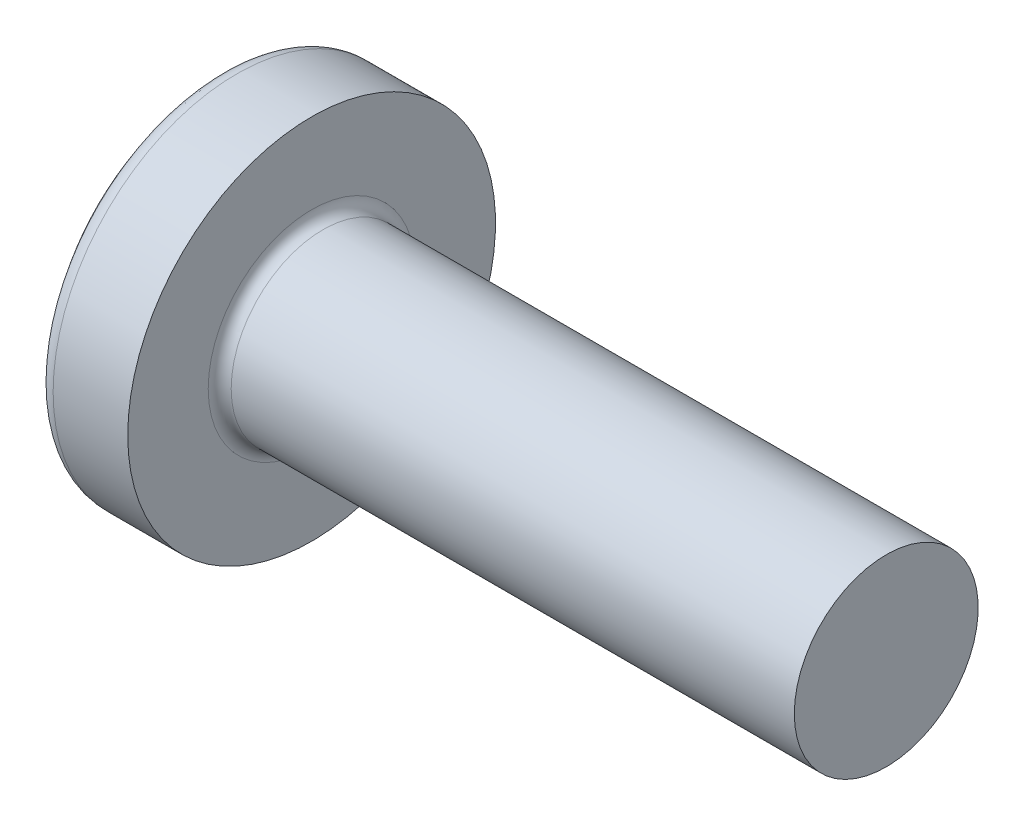
from build123d import *

# Parameters (mm, degrees)
FILLET1_R    = 0.1
SKETCH3_W    = 0.48
SKETCH3_H    = 1.6
SKETCH4_W    = 0.48
SKETCH4_H    = 0.702553256
RECPAT_COUNT = 2
RECPAT_ANGLE = 90


with BuildPart() as part:
    # BodySke → Base-Revolve (revolve)
    with BuildSketch(Plane.XY):
        with BuildLine():
            Line((1.3, 0.8), (1.3, 1.6))
            Line((1.3, 1.6), (0.650675799, 1.6))
            ThreePointArc((0.650675799, 1.6), (0.585036553, 1.584875829), (0.532633829, 1.542553191))
            ThreePointArc((0.532633829, 1.542553191), (0.136907172, 0.815960959), (0, 0))
            Line((0, 0), (6.3, 0))
            Line((6.3, 0), (6.3, 0.8))
            Line((6.3, 0.8), (1.3, 0.8))
        make_face()
    revolve(axis=Axis((-25.4, 0, 0), (1, 0, 0)))

    # Fillet1
    fillet1_edges = [part.edges().sort_by_distance(p)[0] for p in [
        (1.3, -0.8, 0),
    ]]
    fillet(fillet1_edges, radius=FILLET1_R)

    # Sketch3 → Recess section 0
    with BuildSketch(Plane(origin=(0, 0, 0), x_dir=(0, 0, -1), z_dir=(1, 0, 0))):
        Rectangle(SKETCH3_W, SKETCH3_H)
    # Sketch4 → Recess section 1
    with BuildSketch(Plane(origin=(0.9, 0, 0), x_dir=(0, 0, -1), z_dir=(1, 0, 0))):
        Rectangle(SKETCH4_W, SKETCH4_H)
    recess = loft(mode=Mode.SUBTRACT)

    # RecPat: Recess ×2 about axis
    recpat_axis = Axis((0, 0, 0), (1, 0, 0))
    for i in range(1, RECPAT_COUNT):
        add(recess.rotate(recpat_axis, i * RECPAT_ANGLE / (RECPAT_COUNT - 1)), mode=Mode.SUBTRACT)

    # RecCorSke → RecessCore (revolve, cut)
    with BuildSketch(Plane.XY):
        Polygon((0, 0), (0, 0.418434131), (0.9, 0.3555), (1.015508952, 0), align=None)
    revolve(axis=Axis((-3.175, 0, 0), (1, 0, 0)), mode=Mode.SUBTRACT)


solid = part.part
